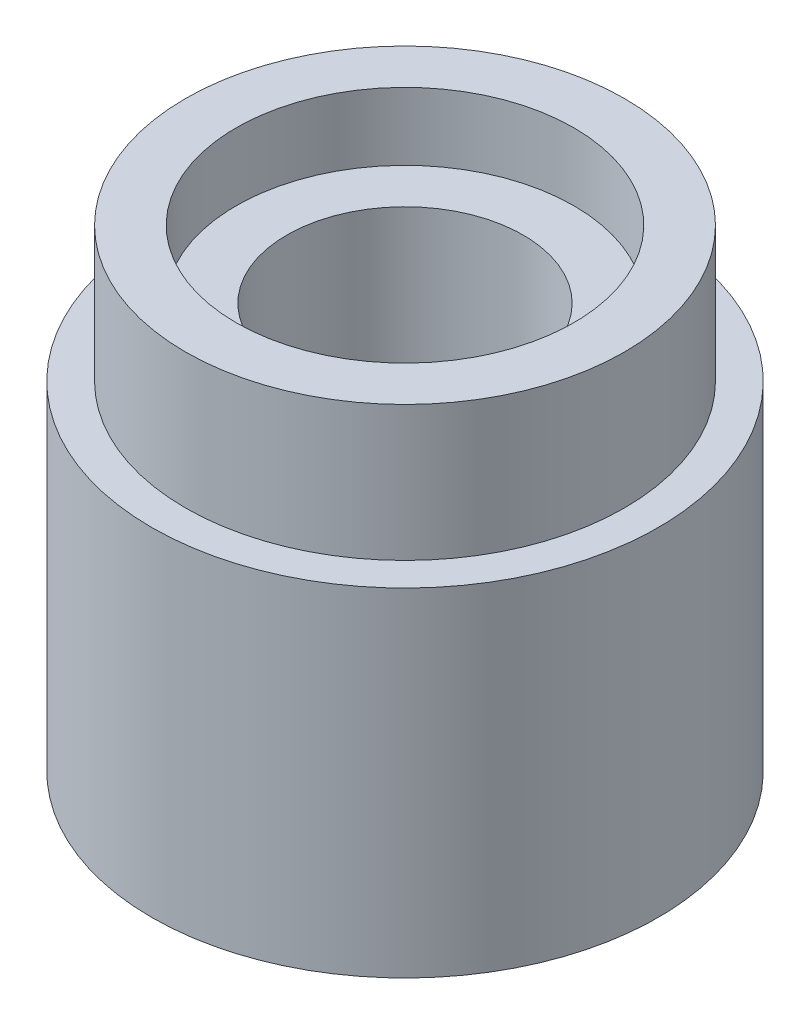
from build123d import *

# Parameters (mm, degrees)
SKETCH1_R           = 3.75
BOSS_EXTRUDE1_DEPTH = 7
SKETCH3_R           = 3.75
SKETCH3_R_2         = 3.25
CUT_EXTRUDE1_DEPTH  = 2
SKETCH4_R           = 1.75
CUT_EXTRUDE2_DEPTH  = 6.5
SKETCH5_R           = 2.5
CUT_EXTRUDE4_DEPTH  = 1


with BuildPart() as part:
    # Sketch1 → Boss-Extrude1 (new body)
    with BuildSketch(Plane(origin=(0, 0, 0), x_dir=(1, 0, 0), z_dir=(0, 1, 0))):
        Circle(SKETCH1_R)
    extrude(amount=BOSS_EXTRUDE1_DEPTH)

    # Sketch3 → Cut-Extrude1 (cut)
    with BuildSketch(Plane(origin=(0, 7, 0), x_dir=(1, 0, 0), z_dir=(0, 1, 0))):
        Circle(SKETCH3_R)
        Circle(SKETCH3_R_2, mode=Mode.SUBTRACT)
    extrude(amount=-CUT_EXTRUDE1_DEPTH, mode=Mode.SUBTRACT)

    # Sketch4 → Cut-Extrude2 (cut)
    with BuildSketch(Plane(origin=(0, 7, 0), x_dir=(1, 0, 0), z_dir=(0, 1, 0))):
        Circle(SKETCH4_R)
    extrude(amount=-CUT_EXTRUDE2_DEPTH, mode=Mode.SUBTRACT)

    # Sketch5 → Cut-Extrude4 (cut)
    with BuildSketch(Plane(origin=(0, 7, 0), x_dir=(1, 0, 0), z_dir=(0, 1, 0))):
        Circle(SKETCH5_R)
    extrude(amount=-CUT_EXTRUDE4_DEPTH, mode=Mode.SUBTRACT)


solid = part.part
